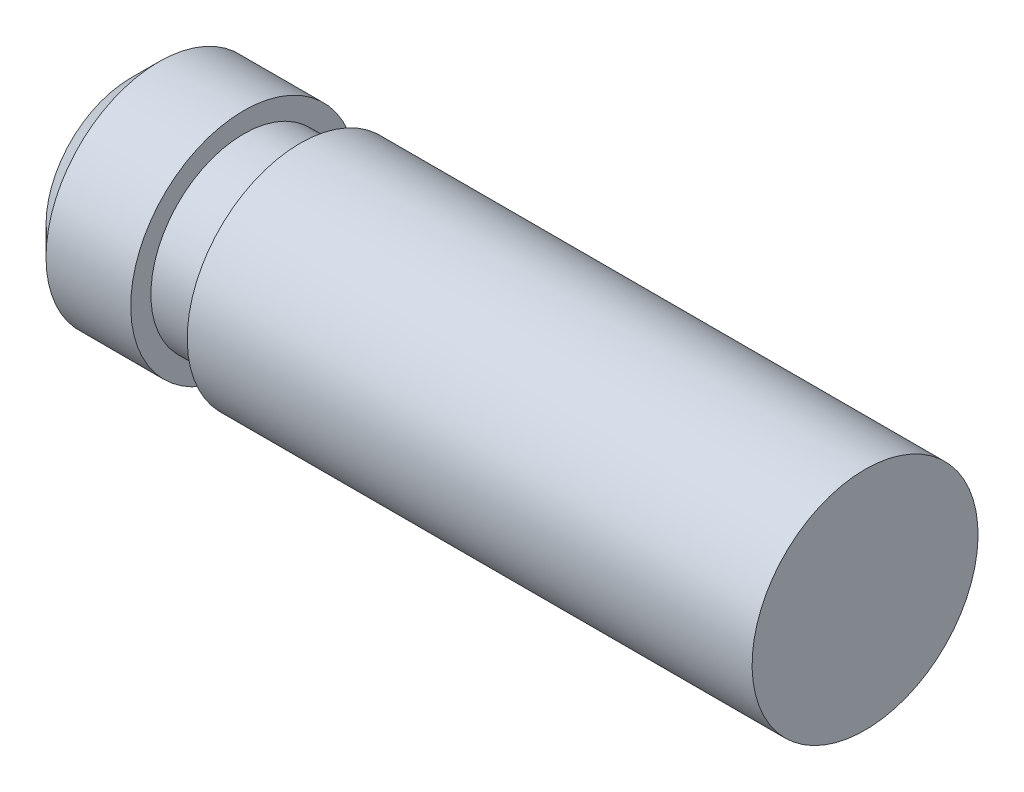
from build123d import *

# Parameters (mm, degrees)
CHAMFER1_SIZE = 0.5


with BuildPart() as part:
    # Sketch1 → Revolve1 (revolve)
    with BuildSketch(Plane.XY):
        Polygon((-4.5, 1.181460584), (-4.5, 0.824815452), (-3.5, 0.824815452), (-3.5, 1.181460584), (6.5, 1.181460584), (6.5, -0.818539416), (-6.5, -0.818539416), (-6.5, 1.181460584), align=None)
    revolve(axis=Axis((6.5, -0.818539416, 0), (-1, 0, 0)))

    # Chamfer1
    chamfer1_edges = [part.edges().sort_by_distance(p)[0] for p in [
        (-6.5, -2.818539416, 0),
    ]]
    chamfer(chamfer1_edges, length=CHAMFER1_SIZE)


solid = part.part
